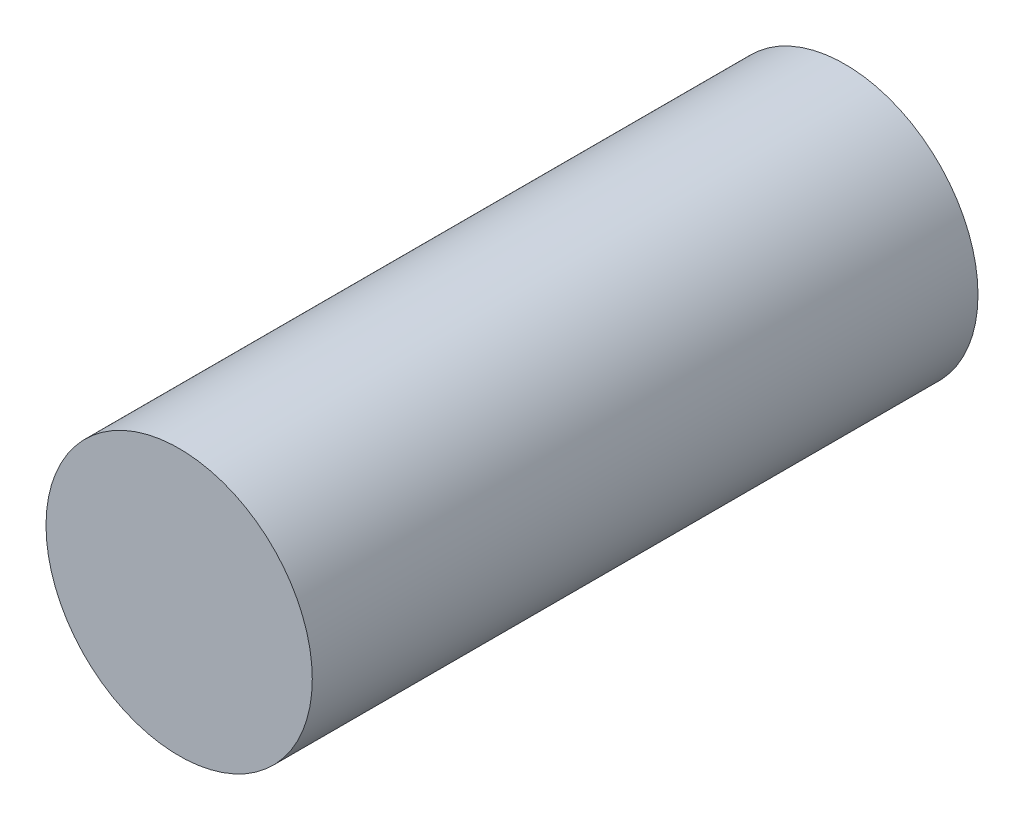
from build123d import *

# Parameters (mm, degrees)
SKETCH_1_R      = 3
EXTRUDE_1_DEPTH = 15


with BuildPart() as part:
    # 草图1 → 凸台-拉伸1 (new body)
    with BuildSketch(Plane.XY):
        with Locations((-3.410619604, 2.357340021)):
            Circle(SKETCH_1_R)
    extrude(amount=EXTRUDE_1_DEPTH)


solid = part.part
